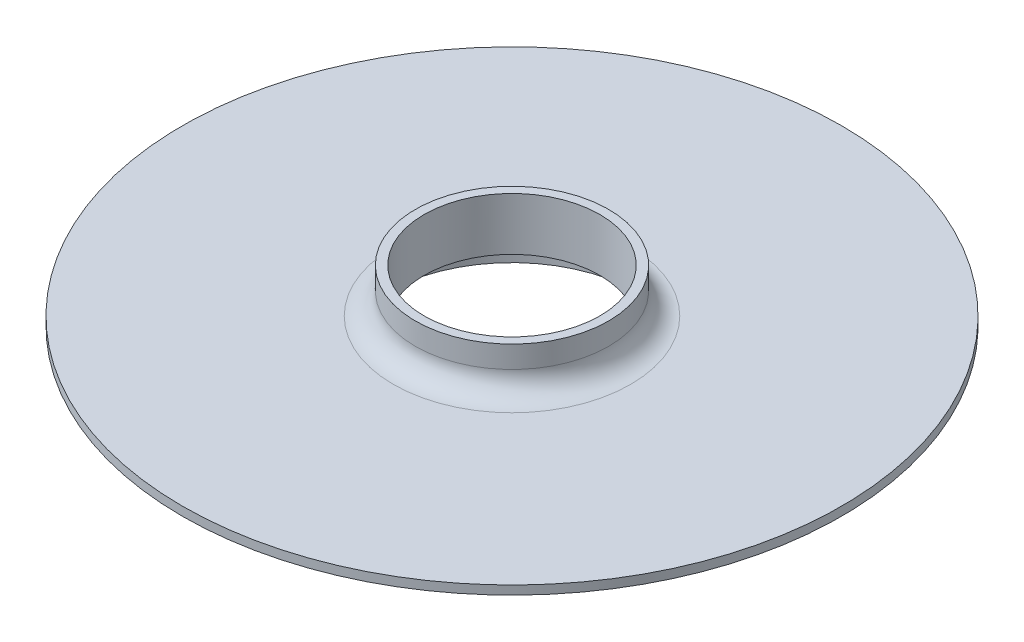
from build123d import *

# Parameters (mm, degrees)
SKETCH1_R           = 75
BOSS_EXTRUDE1_DEPTH = 2
SKETCH2_R           = 31
SKETCH2_R_2         = 29
EXTRUDE_THIN1_DEPTH = 8
SKETCH3_R           = 20
CUT_EXTRUDE1_DEPTH  = 3
SKETCH4_R           = 22
SKETCH4_R_2         = 20
EXTRUDE_THIN2_DEPTH = 10
FILLET1_R           = 5


with BuildPart() as part:
    # Sketch1 → Boss-Extrude1 (new body)
    with BuildSketch(Plane(origin=(0, 0, 0), x_dir=(1, 0, 0), z_dir=(0, 1, 0))):
        Circle(SKETCH1_R)
    extrude(amount=BOSS_EXTRUDE1_DEPTH)

    # Sketch2 → Extrude-Thin1 (add)
    with BuildSketch(Plane.XZ):
        Circle(SKETCH2_R)
        Circle(SKETCH2_R_2, mode=Mode.SUBTRACT)
    extrude(amount=EXTRUDE_THIN1_DEPTH)

    # Sketch3 → Cut-Extrude1 (cut, through all)
    with BuildSketch(Plane.XZ):
        Circle(SKETCH3_R)
    extrude(amount=-CUT_EXTRUDE1_DEPTH, mode=Mode.SUBTRACT)

    # Sketch4 → Extrude-Thin2 (add)
    with BuildSketch(Plane(origin=(0, 2, 0), x_dir=(1, 0, 0), z_dir=(0, 1, 0))):
        Circle(SKETCH4_R)
        Circle(SKETCH4_R_2, mode=Mode.SUBTRACT)
    extrude(amount=EXTRUDE_THIN2_DEPTH)

    # Fillet1
    fillet1_edges = [part.edges().sort_by_distance(p)[0] for p in [
        (-22, 2, 0),
    ]]
    fillet(fillet1_edges, radius=FILLET1_R)


solid = part.part
